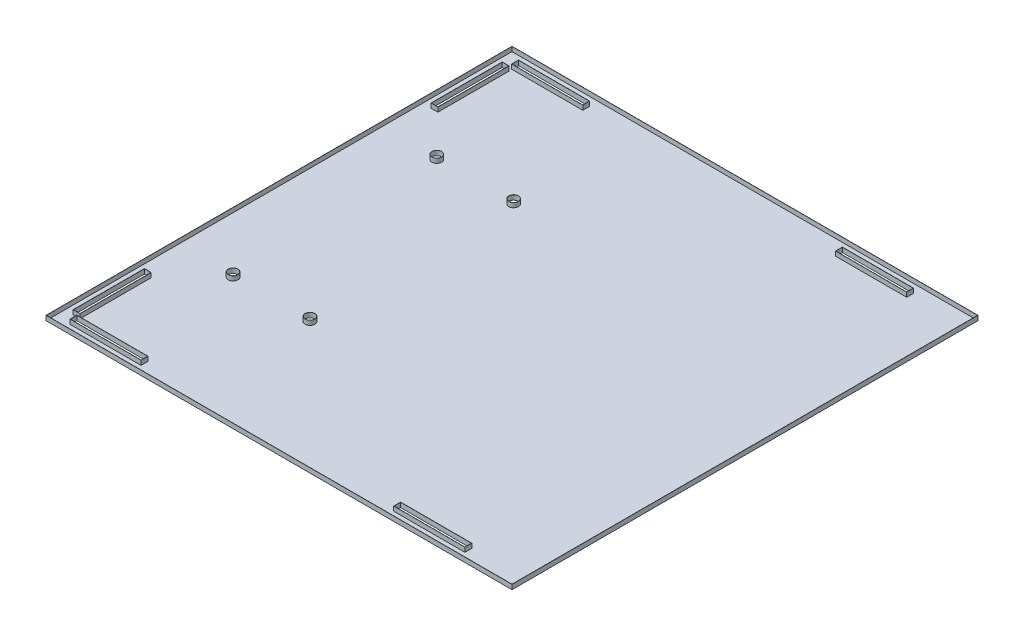
from build123d import *

# Parameters (mm, degrees)
SKETCH1_W                  = 254
SKETCH1_H                  = 127
SKETCH1_W_2                = 38.608
SKETCH1_H_2                = 3.556
SKETCH1_W_3                = 3.556
SKETCH1_H_3                = 38.608
BOSS_EXTRUDE1_DEPTH        = 2.54
F_7_0_201_DIAMETER_HOLE1_D = 5.1054
SHELL1_T                   = -0.1016


with BuildPart() as part:
    # Sketch1 → Boss-Extrude1 (new body)
    with BuildSketch(Plane(origin=(0, 0, 0), x_dir=(1, 0, 0), z_dir=(0, 1, 0))):
        with Locations((127, 0)):
            Rectangle(SKETCH1_W, SKETCH1_H)
        with Locations((27.686, 56.896)):
            Rectangle(SKETCH1_W_2, SKETCH1_H_2, mode=Mode.SUBTRACT)
        with Locations((204.216, 56.896)):
            Rectangle(SKETCH1_W_2, SKETCH1_H_2, mode=Mode.SUBTRACT)
        with Locations((6.604, 34.036)):
            Rectangle(SKETCH1_W_3, SKETCH1_H_3, mode=Mode.SUBTRACT)
    boss_extrude1 = extrude(amount=BOSS_EXTRUDE1_DEPTH)

    # #7 (0.201) Diameter Hole1 (through all)
    with Locations(Plane(origin=(30.48, 2.54, 7.9756), x_dir=(0, 0, 1), z_dir=(0, 1, 0))):
        with Locations((0, 0), (0, 41.91)):
            f_7_0_201_diameter_hole1 = Hole(F_7_0_201_DIAMETER_HOLE1_D / 2)

    # Mirror1: Boss-Extrude1, #7 (0.201) Diameter Hole1 across plane
    add(boss_extrude1.mirror(Plane(origin=(0, 2.54, 63.5), x_dir=(1, 0, 0), z_dir=(0, 0, -1))))
    add(f_7_0_201_diameter_hole1.mirror(Plane(origin=(0, 2.54, 63.5), x_dir=(1, 0, 0), z_dir=(0, 0, -1))), mode=Mode.SUBTRACT)

    # Shell1
    shell1_openings = [part.faces().sort_by_distance(p)[0] for p in [
        (30.48, 2.54, 121.5771),
    ]]
    offset(amount=SHELL1_T, openings=shell1_openings, kind=Kind.INTERSECTION)


solid = part.part
